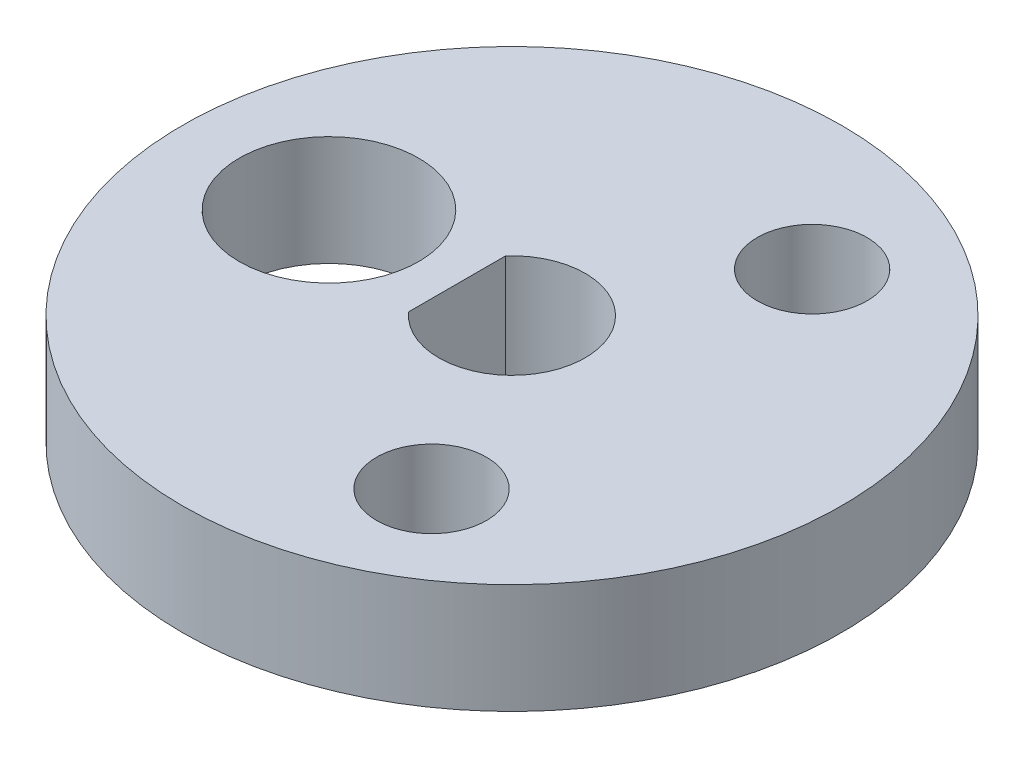
from build123d import *

# Parameters (mm, degrees)
SKETCH1_R           = 9
SKETCH1_R_2         = 2.45
SKETCH1_R_3         = 1.5
BOSS_EXTRUDE1_DEPTH = 3


with BuildPart() as part:
    # Sketch1 → Boss-Extrude1 (new body)
    with BuildSketch(Plane(origin=(0, 0, 0), x_dir=(1, 0, 0), z_dir=(0, 1, 0))):
        Circle(SKETCH1_R)
        with Locations((-5, 0.000835232)):
            Circle(SKETCH1_R_2, mode=Mode.SUBTRACT)
        with Locations((2.999131959, -5.19665349)):
            Circle(SKETCH1_R_3, mode=Mode.SUBTRACT)
        with Locations((3.000867957, 5.195651211)):
            Circle(SKETCH1_R_3, mode=Mode.SUBTRACT)
        with BuildLine():
            Line((-1.499778997, 1.323126207), (-1.500220961, -1.322625067))
            ThreePointArc((-1.500220961, -1.322625067), (1.999999972, -0.000334093), (-1.499778997, 1.323126207))
        make_face(mode=Mode.SUBTRACT)
    extrude(amount=BOSS_EXTRUDE1_DEPTH)


solid = part.part
